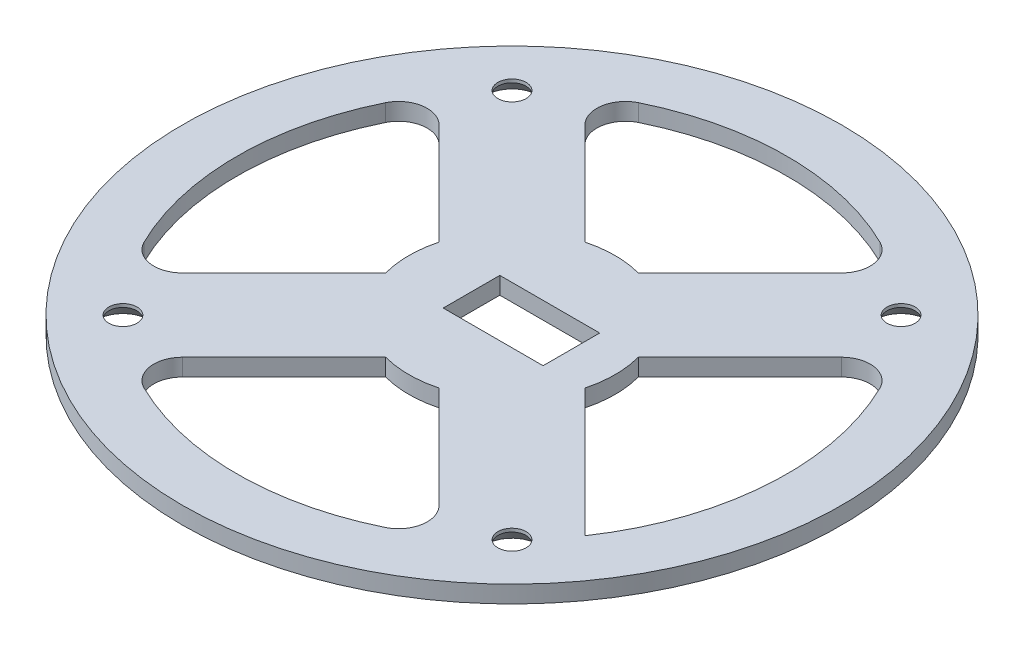
from build123d import *

# Parameters (mm, degrees)
SKETCH1_R                                     = 57.5
SKETCH1_R_2                                   = 0.5
SKETCH1_W                                     = 9.3
SKETCH1_H                                     = 9.875
BOSS_EXTRUDE1_DEPTH                           = 3
CSK_FOR_8_FLAT_HEAD_SOCKET_CAP_SCREW1_A_COUNT = 2
CSK_FOR_8_FLAT_HEAD_SOCKET_CAP_SCREW1_A_PITCH = 67.882250994
CSK_FOR_8_FLAT_HEAD_SOCKET_CAP_SCRE_2_COUNT   = 2
CSK_FOR_8_FLAT_HEAD_SOCKET_CAP_SCRE_2_PITCH   = 96
CSK_FOR_8_FLAT_HEAD_SOCKET_CAP_SCRE_3_COUNT   = 2
CSK_FOR_8_FLAT_HEAD_SOCKET_CAP_SCRE_3_PITCH   = 67.882250994
CUT_EXTRUDE1_DEPTH                            = 4
FILLET1_R                                     = 5
SKETCH5_W                                     = 4.0625
SKETCH5_H                                     = 9.875
CUT_EXTRUDE2_DEPTH                            = 4


with BuildPart() as part:
    # Sketch1 → Boss-Extrude1 (new body)
    with BuildSketch(Plane(origin=(0, 0, 0), x_dir=(1, 0, 0), z_dir=(0, 1, 0))):
        Circle(SKETCH1_R)
        with Locations((-33.941125497, 33.941125497)):
            Circle(SKETCH1_R_2, mode=Mode.SUBTRACT)
        with Locations((33.941125497, 33.941125497)):
            Circle(SKETCH1_R_2, mode=Mode.SUBTRACT)
        with Locations((33.941125497, -33.941125497)):
            Circle(SKETCH1_R_2, mode=Mode.SUBTRACT)
        with Locations((-33.941125497, -33.941125497)):
            Circle(SKETCH1_R_2, mode=Mode.SUBTRACT)
        with Locations((1.65, 0)):
            Rectangle(SKETCH1_W, SKETCH1_H, mode=Mode.SUBTRACT)
    extrude(amount=BOSS_EXTRUDE1_DEPTH)

    # Sketch2 → CSK for #8 Flat Head Socket Cap Screw1 (revolve, cut)
    with BuildSketch(Plane(origin=(-33.941125497, 0, 33.941125497), x_dir=(0, 0, -1), z_dir=(1, 0, 0))):
        Polygon((0, 0), (0, 3), (2.45745, 3), (2.45745, 2.417901837), (4.5593, 0), align=None)
    csk_for_8_flat_head_socket_cap_screw1 = revolve(axis=Axis((-33.941125497, -6.35, 33.941125497), (0, 1, 0)), mode=Mode.SUBTRACT)

    # CSK for #8 Flat Head Socket Cap Screw1 a: CSK for #8 Flat Head Socket Cap Screw1 ×2
    with Locations(*[(i * CSK_FOR_8_FLAT_HEAD_SOCKET_CAP_SCREW1_A_PITCH, 0, 0) for i in range(1, CSK_FOR_8_FLAT_HEAD_SOCKET_CAP_SCREW1_A_COUNT)]):
        add(csk_for_8_flat_head_socket_cap_screw1, mode=Mode.SUBTRACT)

    # CSK for _8 Flat Head Socket Cap Scre 2: CSK for #8 Flat Head Socket Cap Screw1 ×2
    with Locations(*[Vector(0.707106781, 0, -0.707106781) * (i * CSK_FOR_8_FLAT_HEAD_SOCKET_CAP_SCRE_2_PITCH) for i in range(1, CSK_FOR_8_FLAT_HEAD_SOCKET_CAP_SCRE_2_COUNT)]):
        add(csk_for_8_flat_head_socket_cap_screw1, mode=Mode.SUBTRACT)

    # CSK for _8 Flat Head Socket Cap Scre 3: CSK for #8 Flat Head Socket Cap Screw1 ×2
    with Locations(*[(0, 0, -i * CSK_FOR_8_FLAT_HEAD_SOCKET_CAP_SCRE_3_PITCH) for i in range(1, CSK_FOR_8_FLAT_HEAD_SOCKET_CAP_SCRE_3_COUNT)]):
        add(csk_for_8_flat_head_socket_cap_screw1, mode=Mode.SUBTRACT)

    # Sketch4 → Cut-Extrude1 (cut, through all)
    with BuildSketch(Plane(origin=(0, 3, 0), x_dir=(1, 0, 0), z_dir=(0, 1, 0))):
        with BuildLine():
            Line((-26.975205126, 39.703127187), (-4.658742812, 17.386664873))
            ThreePointArc((-4.658742812, 17.386664873), (0, 18), (4.658742812, 17.386664873))
            Line((4.658742812, 17.386664873), (26.975205126, 39.703127187))
            ThreePointArc((26.975205126, 39.703127187), (0, 48), (-26.975205126, 39.703127187))
        make_face()
        with BuildLine():
            Line((39.703127187, 26.975205126), (17.386664873, 4.658742812))
            ThreePointArc((17.386664873, 4.658742812), (18, 0), (17.386664873, -4.658742812))
            Line((17.386664873, -4.658742812), (39.703127187, -26.975205126))
            ThreePointArc((39.703127187, -26.975205126), (48, 0), (39.703127187, 26.975205126))
        make_face()
        with BuildLine():
            Line((26.975205126, -39.703127187), (4.658742812, -17.386664873))
            ThreePointArc((4.658742812, -17.386664873), (0, -18), (-4.658742812, -17.386664873))
            Line((-4.658742812, -17.386664873), (-26.975205126, -39.703127187))
            ThreePointArc((-26.975205126, -39.703127187), (0, -48), (26.975205126, -39.703127187))
        make_face()
        with BuildLine():
            Line((-39.703127187, -26.975205126), (-17.386664873, -4.658742812))
            ThreePointArc((-17.386664873, -4.658742812), (-18, 0), (-17.386664873, 4.658742812))
            Line((-17.386664873, 4.658742812), (-39.703127187, 26.975205126))
            ThreePointArc((-39.703127187, 26.975205126), (-48, 0), (-39.703127187, -26.975205126))
        make_face()
    extrude(amount=-CUT_EXTRUDE1_DEPTH, mode=Mode.SUBTRACT)

    # Fillet1
    fillet1_edges = [part.edges().sort_by_distance(p)[0] for p in [
        (-39.703127187, 1.5, 26.975205126),
        (-39.703127187, 1.5, -26.975205126),
        (-26.975205126, 1.5, -39.703127187),
        (26.975205126, 1.5, -39.703127187),
        (39.703127187, 1.5, -26.975205126),
        (26.975205126, 1.5, 39.703127187),
        (-26.975205126, 1.5, 39.703127187),
    ]]
    fillet(fillet1_edges, radius=FILLET1_R)

    # Sketch5 → Cut-Extrude2 (cut, through all)
    with BuildSketch(Plane.XZ):
        with Locations((8.33125, 0)):
            Rectangle(SKETCH5_W, SKETCH5_H)
        with Locations((-5.03125, 0)):
            Rectangle(SKETCH5_W, SKETCH5_H)
    extrude(amount=-CUT_EXTRUDE2_DEPTH, mode=Mode.SUBTRACT)


solid = part.part
